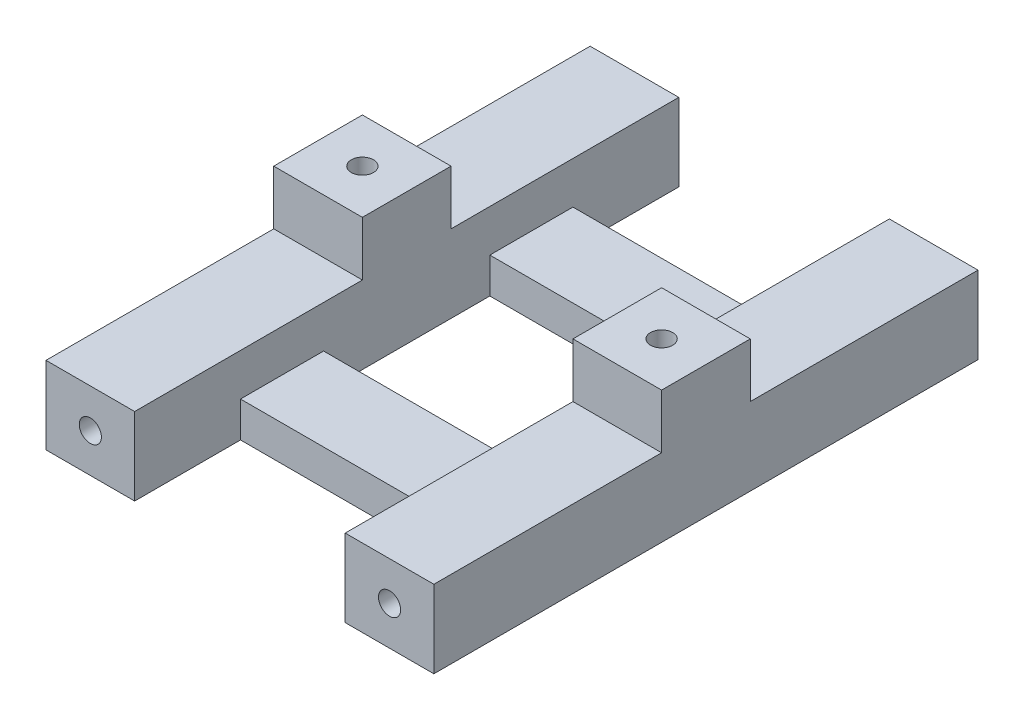
from build123d import *

# Parameters (mm, degrees)
CROQUIS1_W              = 19
CROQUIS1_H              = 15
SALIENTE_EXTRUIR1_DEPTH = 7
CROQUIS2_W              = 8
CROQUIS2_H              = 8
CROQUIS2_R              = 1
SALIENTE_EXTRUIR2_DEPTH = 4.9
CROQUIS3_W              = 19
CROQUIS3_H              = 3.8
CORTAR_EXTRUIR1_DEPTH   = 37.9
CROQUIS4_R              = 1
CORTAR_EXTRUIR2_DEPTH   = 51.9


with BuildPart() as part:
    # Croquis1 → Saliente-Extruir1 (new body)
    with BuildSketch(Plane(origin=(0, 0, 0), x_dir=(1, 0, 0), z_dir=(0, 1, 0))):
        Polygon((16.592354246, -24.663454956), (16.592354246, 24.436543518), (8.592354246, 24.436543518), (8.592354246, 14.886544281), (-10.407645754, 14.886544281), (-10.407645754, 24.436543518), (-18.407645754, 24.436543518), (-18.407645754, -24.663454956), (-10.407645754, -24.663454956), (-10.407645754, -15.113455719), (8.592354246, -15.113455719), (8.592354246, -24.663454956), align=None)
        with Locations((-0.907645754, -0.113455719)):
            Rectangle(CROQUIS1_W, CROQUIS1_H, mode=Mode.SUBTRACT)
    extrude(amount=SALIENTE_EXTRUIR1_DEPTH)

    # Croquis2 → Saliente-Extruir2 (add)
    with BuildSketch(Plane(origin=(0, 7, 0), x_dir=(1, 0, 0), z_dir=(0, 1, 0))):
        with Locations((-14.407645754, -0.113455719)):
            Rectangle(CROQUIS2_W, CROQUIS2_H)
        with Locations((-14.407645754, -0.113455719)):
            Circle(CROQUIS2_R, mode=Mode.SUBTRACT)
        with Locations((12.592354246, -0.113455719)):
            Rectangle(CROQUIS2_W, CROQUIS2_H)
        with Locations((12.592354246, -0.113455719)):
            Circle(CROQUIS2_R, mode=Mode.SUBTRACT)
    extrude(amount=SALIENTE_EXTRUIR2_DEPTH)

    # Croquis3 → Cortar-Extruir1 (cut)
    with BuildSketch(Plane.XY.offset(15.113455719)):
        with Locations((-0.907645754, 5.1)):
            Rectangle(CROQUIS3_W, CROQUIS3_H)
    extrude(amount=-CORTAR_EXTRUIR1_DEPTH, mode=Mode.SUBTRACT)

    # Croquis4 → Cortar-Extruir2 (cut)
    with BuildSketch(Plane.XY.offset(24.663454956)):
        with Locations((12.592354246, 3.5)):
            Circle(CROQUIS4_R)
        with Locations((-14.407645754, 3.5)):
            Circle(CROQUIS4_R)
    extrude(amount=-CORTAR_EXTRUIR2_DEPTH, mode=Mode.SUBTRACT)


solid = part.part
